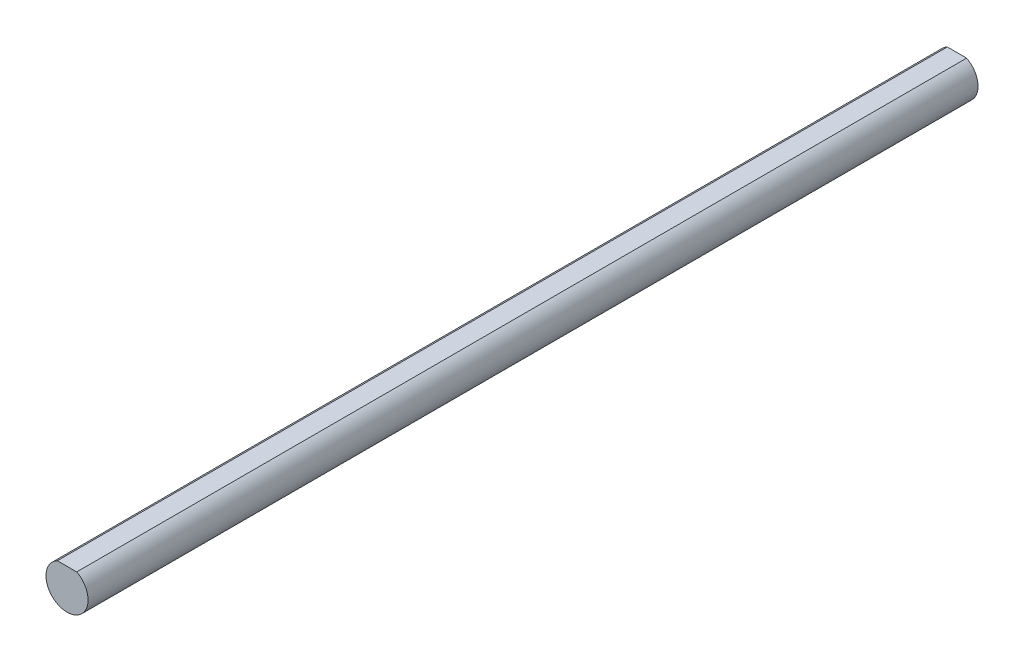
from build123d import *

# Parameters (mm, degrees)
BOSS_EXTRUDE1_DEPTH = 100


with BuildPart() as part:
    # Sketch1 → Boss-Extrude1 (new body)
    with BuildSketch(Plane.XY.offset(50)):
        with BuildLine():
            Line((1.087761463, 2.1), (-1.087761463, 2.1))
            ThreePointArc((-1.087761463, 2.1), (0, -2.365), (1.087761463, 2.1))
        make_face()
    extrude(amount=-BOSS_EXTRUDE1_DEPTH)


solid = part.part
